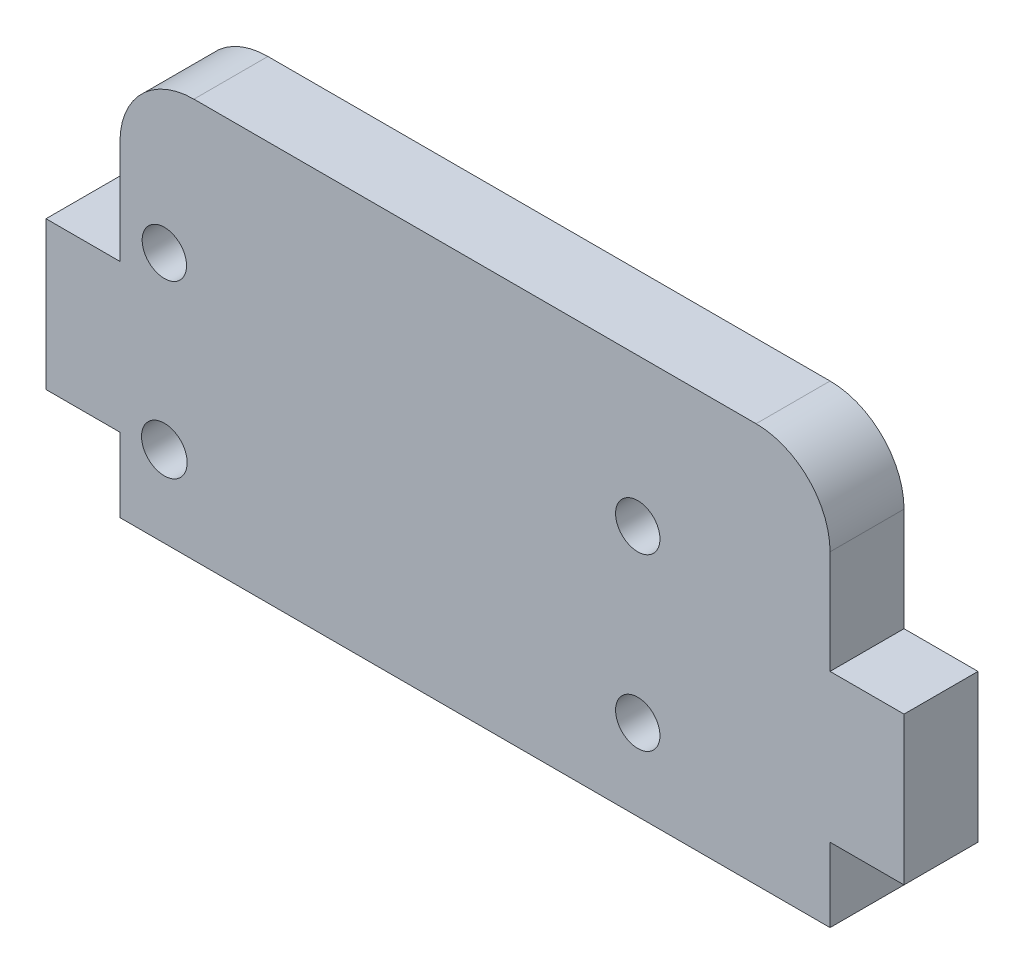
from build123d import *

# Parameters (mm, degrees)
SKETCH1_R           = 1.5
SKETCH1_R_2         = 1.542918724
SKETCH1_R_3         = 1.500000001
BOSS_EXTRUDE1_DEPTH = 5
FILLET1_R           = 5
FILLET2_R           = 5


with BuildPart() as part:
    # Sketch1 → Boss-Extrude1 (new body)
    with BuildSketch(Plane.XY):
        Polygon((-19.733524355, 0), (28.266475645, 0), (28.266475645, 5), (33.266475645, 5), (33.266475645, 15), (28.266475645, 15), (28.266475645, 27), (-19.733524355, 27), (-19.733524355, 15), (-24.733524355, 15), (-24.733524355, 5), (-19.733524355, 5), align=None)
        with Locations((-16.733524355, 17)):
            Circle(SKETCH1_R, mode=Mode.SUBTRACT)
        with Locations((-16.733524356, 5.488599349)):
            Circle(SKETCH1_R_2, mode=Mode.SUBTRACT)
        with Locations((15.266475644, 17)):
            Circle(SKETCH1_R_3, mode=Mode.SUBTRACT)
        with Locations((15.266475644, 5.488599348)):
            Circle(SKETCH1_R_3, mode=Mode.SUBTRACT)
    extrude(amount=BOSS_EXTRUDE1_DEPTH)

    # Fillet1
    fillet1_edges = [part.edges().sort_by_distance(p)[0] for p in [
        (-19.733524355, 27, 2.5),
    ]]
    fillet(fillet1_edges, radius=FILLET1_R)

    # Fillet2
    fillet2_edges = [part.edges().sort_by_distance(p)[0] for p in [
        (28.266475645, 27, 2.5),
    ]]
    fillet(fillet2_edges, radius=FILLET2_R)


solid = part.part
